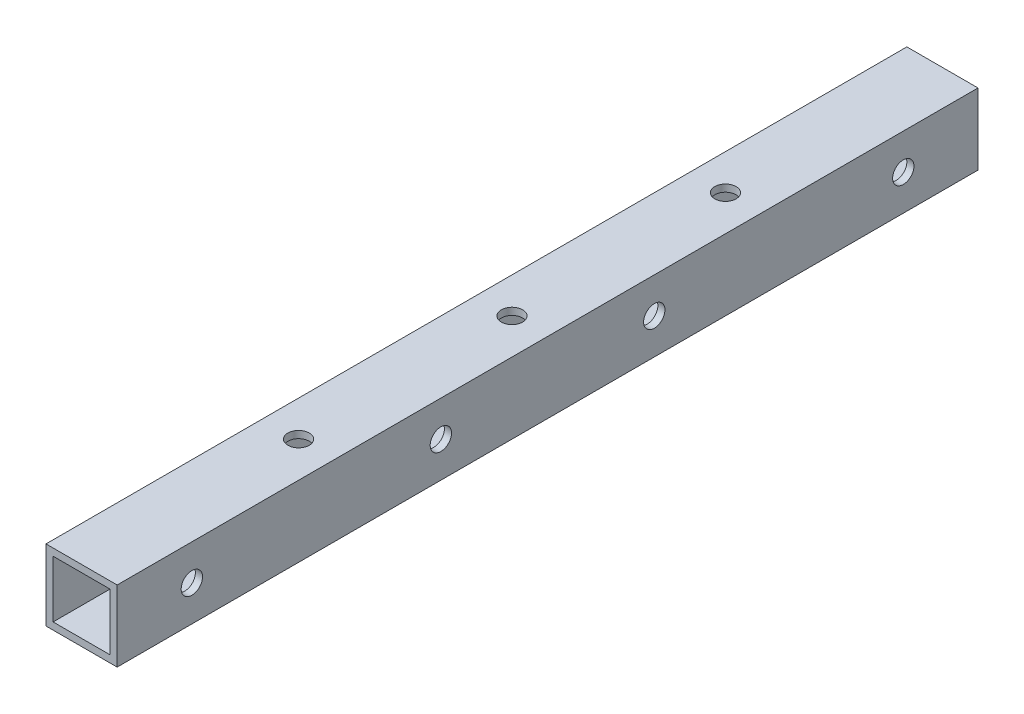
from build123d import *

# Parameters (mm, degrees)
SKETCH_1_W          = 10
SKETCH_1_H          = 10
SKETCH_1_W_2        = 8
SKETCH_1_H_2        = 8
EXTRUDE_1_DEPTH     = 121
SKETCH_2_R          = 1.5
CUT_EXTRUDE_1_DEPTH = 11
SKETCH_3_R          = 1.5
CUT_EXTRUDE_2_DEPTH = 11


with BuildPart() as part:
    # 草图1 → 拉伸-薄壁1 (new body)
    with BuildSketch(Plane.XY):
        Rectangle(SKETCH_1_W, SKETCH_1_H)
        Rectangle(SKETCH_1_W_2, SKETCH_1_H_2, mode=Mode.SUBTRACT)
    extrude(amount=EXTRUDE_1_DEPTH)

    # 草图2 → 切除-拉伸1 (cut, through all)
    with BuildSketch(Plane(origin=(5, 0, 0), x_dir=(0, 0, -1), z_dir=(1, 0, 0))):
        with Locations((-110.5, 0)):
            Circle(SKETCH_2_R)
        with Locations((-75.5, 0)):
            Circle(SKETCH_2_R)
        with Locations((-45.5, 0)):
            Circle(SKETCH_2_R)
        with Locations((-10.5, 0)):
            Circle(SKETCH_2_R)
    extrude(amount=-CUT_EXTRUDE_1_DEPTH, mode=Mode.SUBTRACT)

    # 草图3 → 切除-拉伸2 (cut, through all)
    with BuildSketch(Plane(origin=(0, 5, 0), x_dir=(1, 0, 0), z_dir=(0, 1, 0))):
        with Locations((0, -60.5)):
            Circle(SKETCH_3_R)
        with Locations((0, -30.5)):
            Circle(SKETCH_3_R)
        with Locations((0, -90.5)):
            Circle(SKETCH_3_R)
    extrude(amount=-CUT_EXTRUDE_2_DEPTH, mode=Mode.SUBTRACT)


solid = part.part
